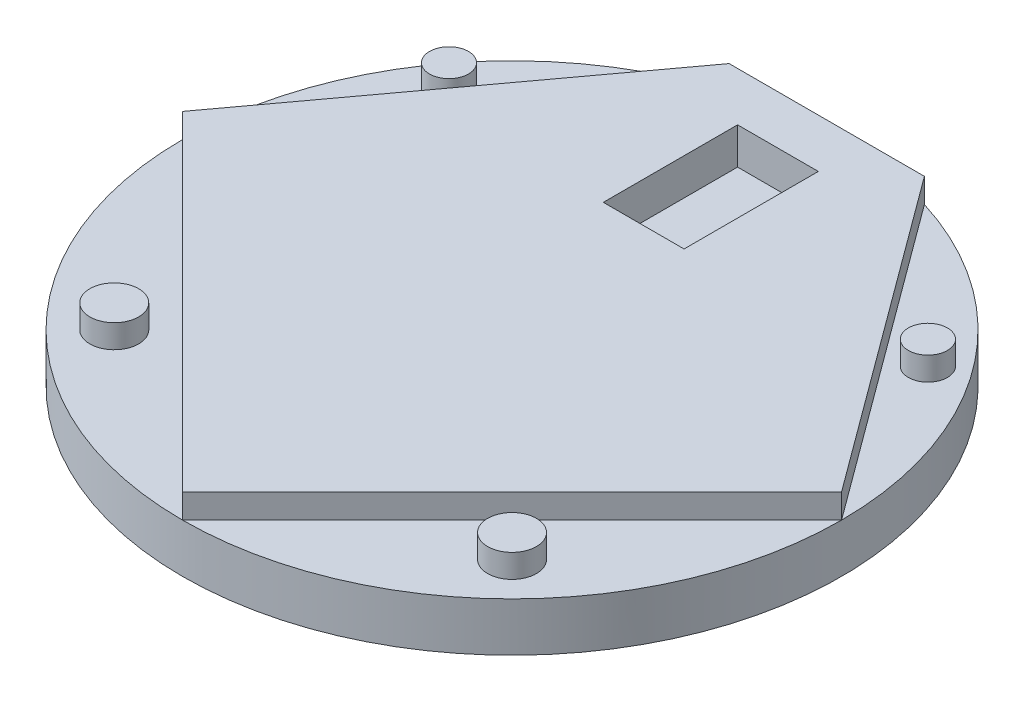
from build123d import *

# Parameters (mm, degrees)
SKETCH1_R           = 85.725
BOSS_EXTRUDE1_DEPTH = 12.7
BOSS_EXTRUDE2_DEPTH = 6.35
SKETCH3_R           = 6.35
SKETCH3_R_2         = 5.08
BOSS_EXTRUDE3_DEPTH = 6.096
SKETCH4_W           = 21.0058
SKETCH4_H           = 34.925
CUT_EXTRUDE1_DEPTH  = 9.525


with BuildPart() as part:
    # Sketch1 → Boss-Extrude1 (new body)
    with BuildSketch(Plane(origin=(0, 0, 0), x_dir=(1, 0, 0), z_dir=(0, 1, 0))):
        Circle(SKETCH1_R)
    extrude(amount=BOSS_EXTRUDE1_DEPTH)

    # Sketch2 → Boss-Extrude2 (add)
    with BuildSketch(Plane(origin=(0, 12.7, 0), x_dir=(1, 0, 0), z_dir=(0, 1, 0))):
        Polygon((-25.4, 81.875610685), (25.4, 81.875610685), (85.725, 0), (0, -85.725), (-85.725, 0), align=None)
    extrude(amount=BOSS_EXTRUDE2_DEPTH)

    # Sketch3 → Boss-Extrude3 (add)
    with BuildSketch(Plane(origin=(0, 12.7, 0), x_dir=(1, 0, 0), z_dir=(0, 1, 0))):
        with Locations((-51.739614409, -51.739614409)):
            Circle(SKETCH3_R)
        with Locations((51.739614409, -51.739614409)):
            Circle(SKETCH3_R)
        with Locations((62.288840877, 45.893695259)):
            Circle(SKETCH3_R_2)
        with Locations((-62.288840877, 45.893695259)):
            Circle(SKETCH3_R_2)
    extrude(amount=BOSS_EXTRUDE3_DEPTH)

    # Sketch4 → Cut-Extrude1 (cut)
    with BuildSketch(Plane(origin=(0, 19.05, 0), x_dir=(1, 0, 0), z_dir=(0, 1, 0))):
        with Locations((0, 51.713110685)):
            Rectangle(SKETCH4_W, SKETCH4_H)
    extrude(amount=-CUT_EXTRUDE1_DEPTH, mode=Mode.SUBTRACT)


solid = part.part
